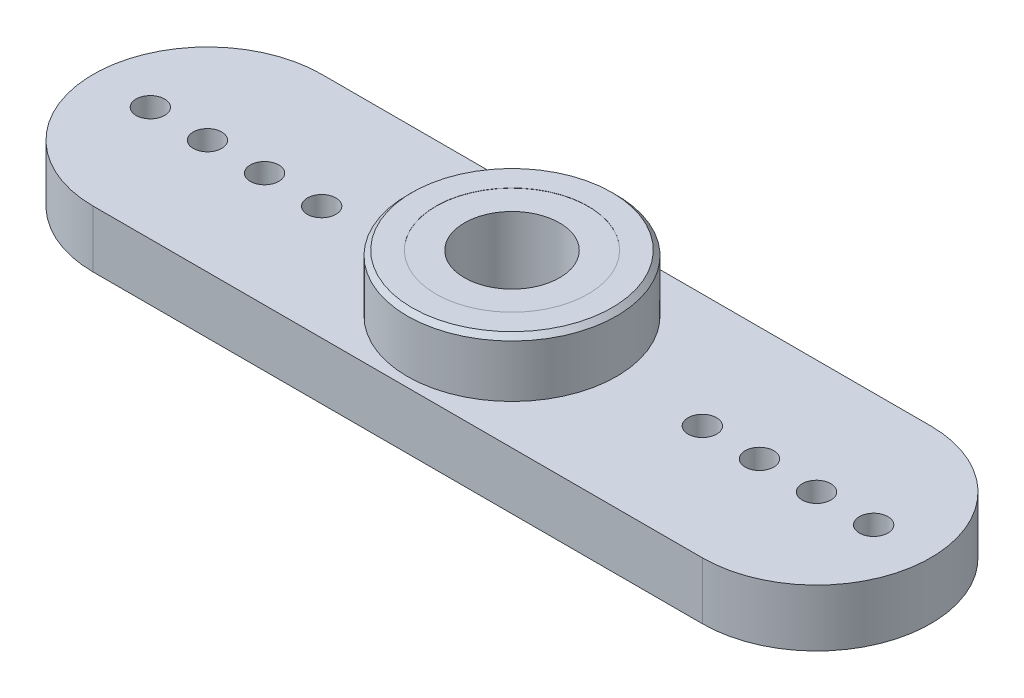
from build123d import *

# Parameters (mm, degrees)
SKETCH1_R           = 0.75
SKETCH1_R_2         = 1.5
BOSS_EXTRUDE1_DEPTH = 3
SKETCH2_R           = 3.5
CUT_EXTRUDE1_DEPTH  = 1.5
SKETCH3_R           = 4
BOSS_EXTRUDE2_DEPTH = 2.99
SKETCH4_R           = 2.5
CUT_EXTRUDE2_DEPTH  = 4
SKETCH5_R           = 5.5
SKETCH5_R_2         = 4
BOSS_EXTRUDE3_DEPTH = 3
CHAMFER1_SIZE       = 0.25


with BuildPart() as part:
    # Sketch1 → Boss-Extrude1 (new body)
    with BuildSketch(Plane(origin=(0, 0, 0), x_dir=(1, 0, 0), z_dir=(0, 1, 0))):
        with BuildLine():
            Line((-16, 6), (16, 6))
            ThreePointArc((16, 6), (22, 0), (16, -6))
            Line((16, -6), (-16, -6))
            ThreePointArc((-16, -6), (-22, 0), (-16, 6))
        make_face()
        with Locations((10, 0)):
            Circle(SKETCH1_R, mode=Mode.SUBTRACT)
        with Locations((13, 0)):
            Circle(SKETCH1_R, mode=Mode.SUBTRACT)
        with Locations((16, 0)):
            Circle(SKETCH1_R, mode=Mode.SUBTRACT)
        with Locations((19, 0)):
            Circle(SKETCH1_R, mode=Mode.SUBTRACT)
        with Locations((-19, 0)):
            Circle(SKETCH1_R, mode=Mode.SUBTRACT)
        with Locations((-16, 0)):
            Circle(SKETCH1_R, mode=Mode.SUBTRACT)
        with Locations((-13, 0)):
            Circle(SKETCH1_R, mode=Mode.SUBTRACT)
        with Locations((-10, 0)):
            Circle(SKETCH1_R, mode=Mode.SUBTRACT)
        Circle(SKETCH1_R_2, mode=Mode.SUBTRACT)
    extrude(amount=BOSS_EXTRUDE1_DEPTH)

    # Sketch2 → Cut-Extrude1 (cut)
    with BuildSketch(Plane(origin=(0, 0, 0), x_dir=(-1, 0, 0), z_dir=(0, -1, 0))):
        Circle(SKETCH2_R)
    extrude(amount=-CUT_EXTRUDE1_DEPTH, mode=Mode.SUBTRACT)

    # Sketch3 → Boss-Extrude2 (add)
    with BuildSketch(Plane(origin=(0, 3, 0), x_dir=(1, 0, 0), z_dir=(0, 1, 0))):
        Circle(SKETCH3_R)
    extrude(amount=BOSS_EXTRUDE2_DEPTH)

    # Sketch4 → Cut-Extrude2 (cut)
    with BuildSketch(Plane(origin=(0, 5.99, 0), x_dir=(1, 0, 0), z_dir=(0, 1, 0))):
        Circle(SKETCH4_R)
    extrude(amount=-CUT_EXTRUDE2_DEPTH, mode=Mode.SUBTRACT)

    # Sketch5 → Boss-Extrude3 (add)
    with BuildSketch(Plane(origin=(0, 3, 0), x_dir=(1, 0, 0), z_dir=(0, 1, 0))):
        Circle(SKETCH5_R)
        Circle(SKETCH5_R_2, mode=Mode.SUBTRACT)
    extrude(amount=BOSS_EXTRUDE3_DEPTH)

    # Chamfer1
    chamfer1_edges = [part.edges().sort_by_distance(p)[0] for p in [
        (-5.5, 6, 0),
    ]]
    chamfer(chamfer1_edges, length=CHAMFER1_SIZE)


solid = part.part
